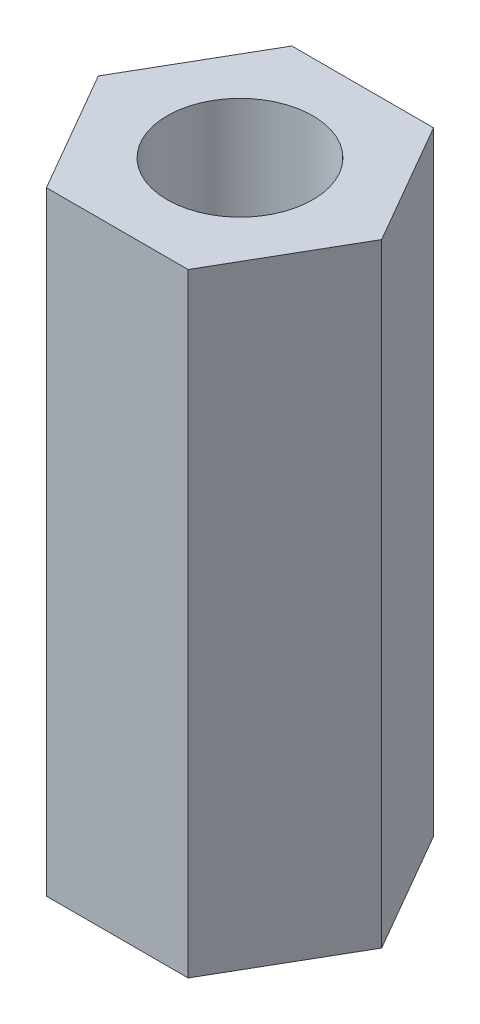
from build123d import *

# Parameters (mm, degrees)
SKETCH1_R           = 1.1303
BOSS_EXTRUDE1_DEPTH = 9.525


with BuildPart() as part:
    # Sketch1 → Boss-Extrude1 (new body)
    with BuildSketch(Plane(origin=(0, 0, 0), x_dir=(1, 0, 0), z_dir=(0, 1, 0))):
        Polygon((1.099852263, -1.905), (2.199704526, 0), (1.099852263, 1.905), (-1.099852263, 1.905), (-2.199704526, 0), (-1.099852263, -1.905), align=None)
        Circle(SKETCH1_R, mode=Mode.SUBTRACT)
    extrude(amount=BOSS_EXTRUDE1_DEPTH)


solid = part.part
